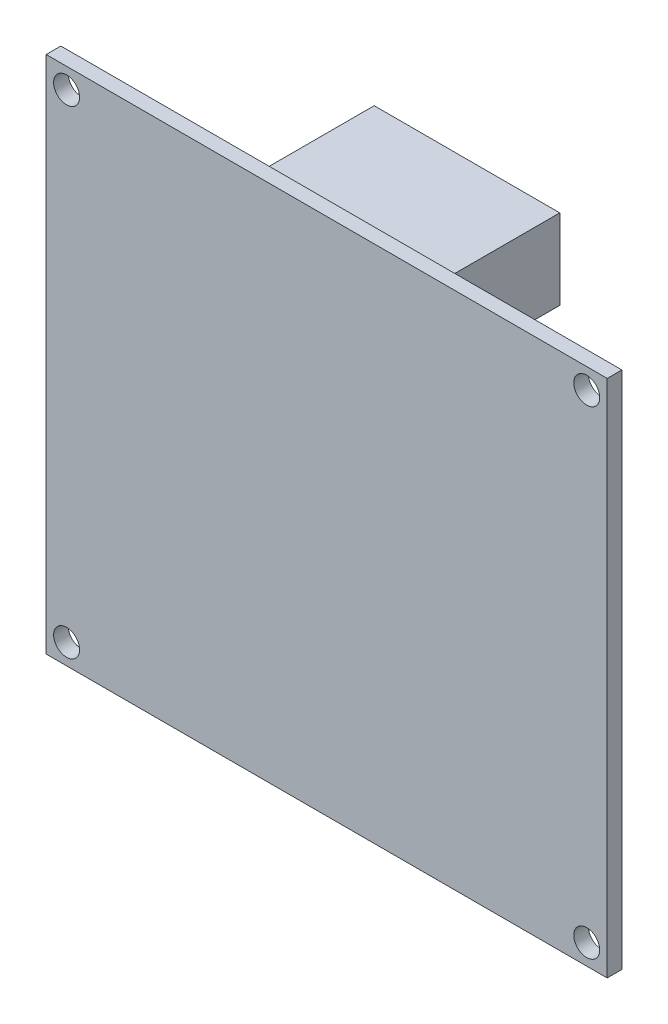
from build123d import *

# Parameters (mm, degrees)
SKETCH1_W           = 63.119
SKETCH1_H           = 58.42
BOSS_EXTRUDE1_DEPTH = 0.8255
SKETCH6_W           = 20.8788
SKETCH6_H           = 9.017
BOSS_EXTRUDE3_DEPTH = 13.081
SKETCH3_R           = 1.4605
CUT_EXTRUDE1_DEPTH  = 46.456110307


with BuildPart() as part:
    # Sketch1 → Boss-Extrude1 (new, symmetric)
    with BuildSketch(Plane.XY):
        Rectangle(SKETCH1_W, SKETCH1_H)
    extrude(amount=BOSS_EXTRUDE1_DEPTH, both=True)

    # Sketch6 → Boss-Extrude3 (add)
    with BuildSketch(Plane(origin=(0, 0, -0.8255), x_dir=(-1, 0, 0), z_dir=(0, 0, -1))):
        with Locations((-1.0541, 23.4315)):
            Rectangle(SKETCH6_W, SKETCH6_H)
    extrude(amount=BOSS_EXTRUDE3_DEPTH)

    # Sketch3 → Cut-Extrude1 (cut, through all)
    with BuildSketch(Plane.XY.offset(0.8255)):
        with Locations((-29.25826, 26.9113)):
            Circle(SKETCH3_R)
        with Locations((29.25826, 26.9113)):
            Circle(SKETCH3_R)
        with Locations((29.25826, -26.9113)):
            Circle(SKETCH3_R)
        with Locations((-29.25826, -26.9113)):
            Circle(SKETCH3_R)
    extrude(amount=-CUT_EXTRUDE1_DEPTH, mode=Mode.SUBTRACT)


solid = part.part
